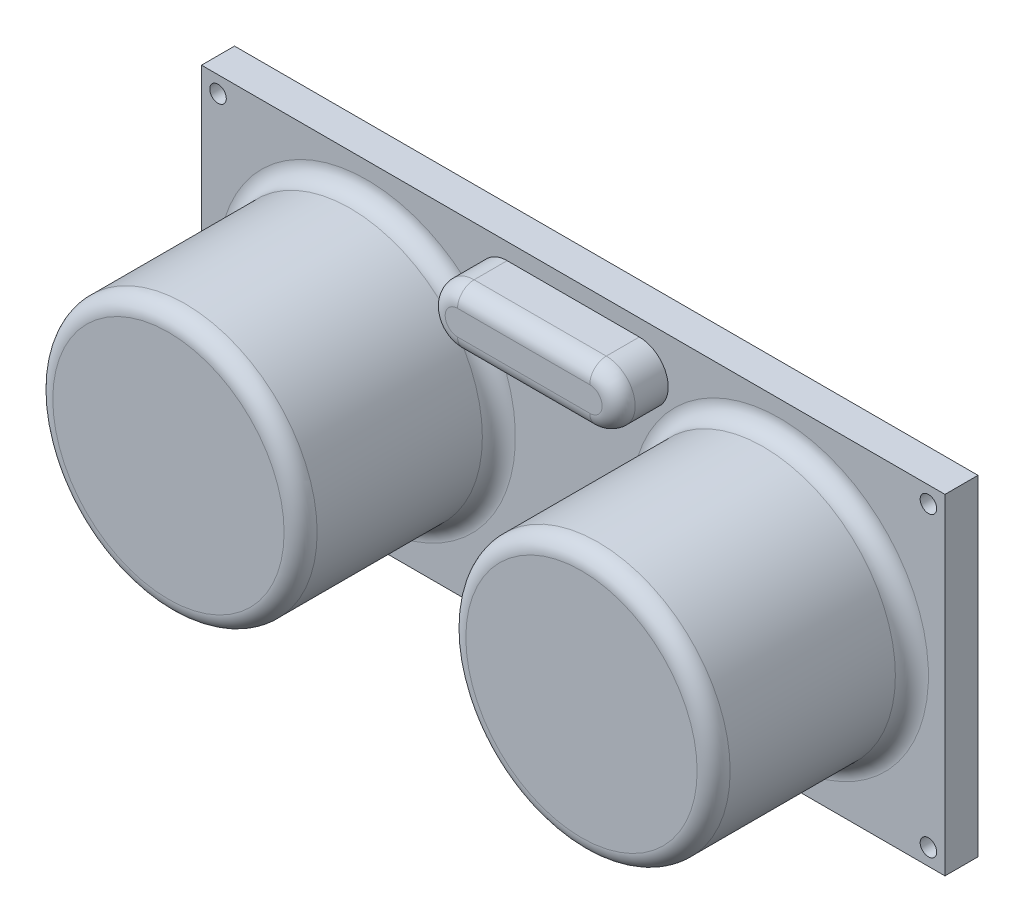
from build123d import *

# Parameters (mm, degrees)
CROQUIS1_W              = 45
CROQUIS1_H              = 20
SALIENTE_EXTRUIR1_DEPTH = 2
CROQUIS2_R              = 8
SALIENTE_EXTRUIR2_DEPTH = 12
REDONDEO1_R             = 1
SALIENTE_EXTRUIR3_DEPTH = 3
REDONDEO2_R             = 1
CROQUIS4_R              = 0.5
CORTAR_EXTRUIR1_DEPTH   = 3
CROQUIS5_W              = 10
CROQUIS5_H              = 3
SALIENTE_EXTRUIR4_DEPTH = 2.54
CHAFL_N1_SIZE           = 0.2
CROQUIS6_W              = 0.7
CROQUIS6_H              = 0.7
SALIENTE_EXTRUIR5_DEPTH = 1
CROQUIS7_W              = 0.7
CROQUIS7_H              = 0.7
REVOLUCI_N1_ANGLE       = 90
CROQUIS8_W              = 0.7
CROQUIS8_H              = 0.7
SALIENTE_EXTRUIR6_DEPTH = 6


with BuildPart() as part:
    # Croquis1 → Saliente-Extruir1 (new body)
    with BuildSketch(Plane.XY):
        Rectangle(CROQUIS1_W, CROQUIS1_H)
    extrude(amount=SALIENTE_EXTRUIR1_DEPTH)

    # Croquis2 → Saliente-Extruir2 (add)
    with BuildSketch(Plane.XY.offset(2)):
        with Locations((12.5, 0)):
            Circle(CROQUIS2_R)
        with Locations((-12.5, 0)):
            Circle(CROQUIS2_R)
    extrude(amount=SALIENTE_EXTRUIR2_DEPTH)

    # Redondeo1
    redondeo1_edges = [part.edges().sort_by_distance(p)[0] for p in [
        (4.5, 0, 2),
        (4.5, 0, 14),
        (-20.5, 0, 2),
        (-20.5, 0, 14),
    ]]
    fillet(redondeo1_edges, radius=REDONDEO1_R)

    # Croquis3 → Saliente-Extruir3 (add)
    with BuildSketch(Plane.XY.offset(2)):
        with BuildLine():
            Line((4, 5.5), (-4, 5.5))
            ThreePointArc((-4, 5.5), (-5.75, 7.25), (-4, 9))
            Line((-4, 9), (4, 9))
            ThreePointArc((4, 9), (5.75, 7.25), (4, 5.5))
        make_face()
    extrude(amount=SALIENTE_EXTRUIR3_DEPTH)

    # Redondeo2
    redondeo2_edges = [part.edges().sort_by_distance(p)[0] for p in [
        (5.75, 7.25, 5),
        (0, 9, 5),
        (-5.75, 7.25, 5),
        (0, 5.5, 5),
    ]]
    fillet(redondeo2_edges, radius=REDONDEO2_R)

    # Croquis4 → Cortar-Extruir1 (cut, through all)
    with BuildSketch(Plane.XY.offset(2)):
        with Locations((21.5, 9)):
            Circle(CROQUIS4_R)
        with Locations((21.5, -9)):
            Circle(CROQUIS4_R)
        with Locations((-21.5, -9)):
            Circle(CROQUIS4_R)
        with Locations((-21.5, 9)):
            Circle(CROQUIS4_R)
    extrude(amount=-CORTAR_EXTRUIR1_DEPTH, mode=Mode.SUBTRACT)

    # Croquis5 → Saliente-Extruir4 (add)
    with BuildSketch(Plane(origin=(0, 0, 0), x_dir=(-1, 0, 0), z_dir=(0, 0, -1))):
        with Locations((0, -8.5)):
            Rectangle(CROQUIS5_W, CROQUIS5_H)
    extrude(amount=SALIENTE_EXTRUIR4_DEPTH)

    # Chaflán1
    chafl_n1_edges = [part.edges().sort_by_distance(p)[0] for p in [
        (5, -7, -1.27),
        (5, -10, -1.27),
        (-5, -10, -1.27),
        (-5, -7, -1.27),
    ]]
    chamfer(chafl_n1_edges, length=CHAFL_N1_SIZE)

    # Croquis6 → Saliente-Extruir5 (add)
    with BuildSketch(Plane(origin=(0, 0, -2.54), x_dir=(-1, 0, 0), z_dir=(0, 0, -1))):
        with Locations((-3.75, -8.5)):
            Rectangle(CROQUIS6_W, CROQUIS6_H)
        with Locations((-1.25, -8.5)):
            Rectangle(CROQUIS6_W, CROQUIS6_H)
        with Locations((1.25, -8.5)):
            Rectangle(CROQUIS6_W, CROQUIS6_H)
        with Locations((3.75, -8.5)):
            Rectangle(CROQUIS6_W, CROQUIS6_H)
    extrude(amount=SALIENTE_EXTRUIR5_DEPTH)

    # Croquis7 → Revolución1 (revolve)
    with BuildSketch(Plane(origin=(0, 0, -3.54), x_dir=(-1, 0, 0), z_dir=(0, 0, -1))):
        with Locations((-3.75, -8.5)):
            Rectangle(CROQUIS7_W, CROQUIS7_H)
        with Locations((-1.25, -8.5)):
            Rectangle(CROQUIS7_W, CROQUIS7_H)
        with Locations((1.25, -8.5)):
            Rectangle(CROQUIS7_W, CROQUIS7_H)
        with Locations((3.75, -8.5)):
            Rectangle(CROQUIS7_W, CROQUIS7_H)
    revolve(axis=Axis((4.1, -9.15, -3.54), (-1, 0, 0)), revolution_arc=REVOLUCI_N1_ANGLE)

    # Croquis8 → Saliente-Extruir6 (add)
    with BuildSketch(Plane.XZ.offset(9.15)):
        with Locations((3.75, -4.19)):
            Rectangle(CROQUIS8_W, CROQUIS8_H)
        with Locations((1.25, -4.19)):
            Rectangle(CROQUIS8_W, CROQUIS8_H)
        with Locations((-1.25, -4.19)):
            Rectangle(CROQUIS8_W, CROQUIS8_H)
        with Locations((-3.75, -4.19)):
            Rectangle(CROQUIS8_W, CROQUIS8_H)
    extrude(amount=SALIENTE_EXTRUIR6_DEPTH)


solid = part.part
